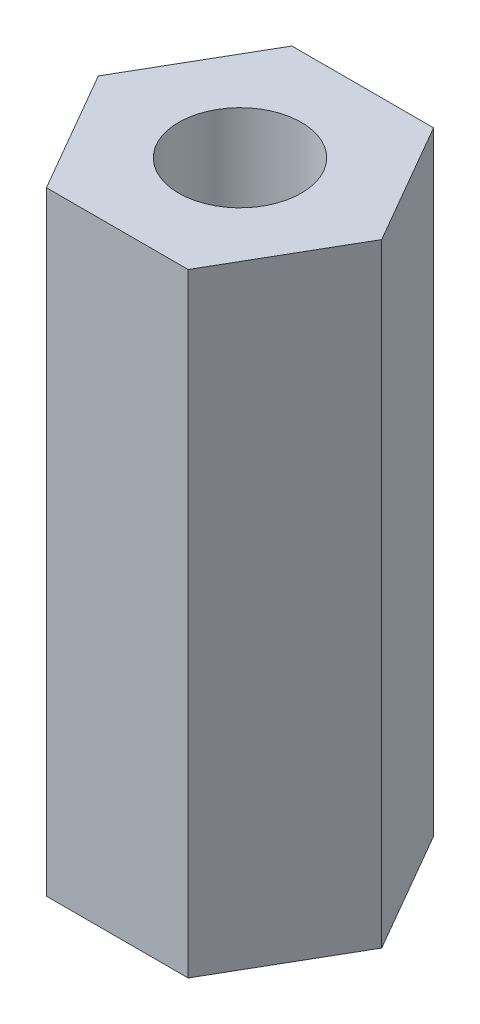
from build123d import *

# Parameters (mm, degrees)
SKETCH1_R           = 1.5
BOSS_EXTRUDE1_DEPTH = 15


with BuildPart() as part:
    # Sketch1 → Boss-Extrude1 (new body)
    with BuildSketch(Plane(origin=(0, 0, 0), x_dir=(1, 0, 0), z_dir=(0, 1, 0))):
        Polygon((3.464101615, 0), (1.732050808, 3), (-1.732050808, 3), (-3.464101615, 0), (-1.732050808, -3), (1.732050808, -3), align=None)
        Circle(SKETCH1_R, mode=Mode.SUBTRACT)
    extrude(amount=BOSS_EXTRUDE1_DEPTH)


solid = part.part
